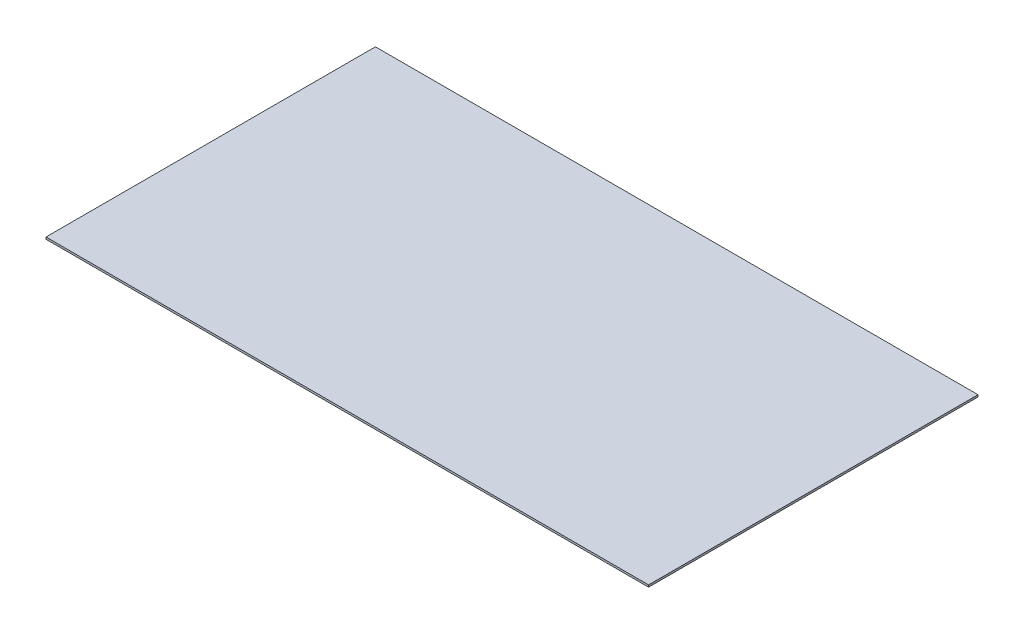
from build123d import *

# Parameters (mm, degrees)
SKETCH1_W           = 476.25
SKETCH1_H           = 260.35
BOSS_EXTRUDE1_DEPTH = 1.5875


with BuildPart() as part:
    # Sketch1 → Boss-Extrude1 (new body)
    with BuildSketch(Plane(origin=(0, 0, 0), x_dir=(1, 0, 0), z_dir=(0, 1, 0))):
        Rectangle(SKETCH1_W, SKETCH1_H)
    extrude(amount=BOSS_EXTRUDE1_DEPTH)


solid = part.part
